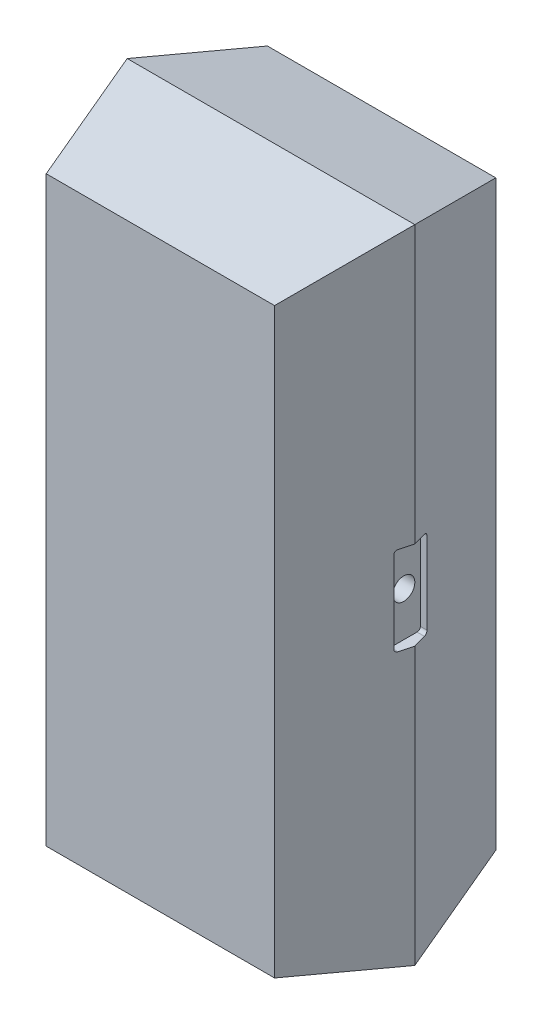
from build123d import *

# Parameters (mm, degrees)
ESBO_O15_W                         = 1.3
ESBO_O15_H                         = 2.9
RESSALTO_EXTRUS_O1_DEPTH           = 0.5
RESSALTO_EXTRUS_O1_TAPER           = 15
RESSALTO_EXTRUS_O1_OTHER_WAY_DEPTH = 0.5
RESSALTO_EXTRUS_O1_OTHER_WAY_TAPER = 15
ESBO_O18_R                         = 0.05
CORTE_EXTRUS_O1_DEPTH              = 1
ESBO_O18_3_R                       = 0.05
CORTE_EXTRUS_O2_DEPTH              = 1
CORTE_EXTRUS_O3_DEPTH              = 0.05
CORTE_EXTRUS_O4_START              = 1.3
CORTE_EXTRUS_O4_DEPTH              = 0.05


with BuildPart() as part:
    # Esbo_o15 → Ressalto-extrus_o1 (new body)
    with BuildSketch(Plane.XY.offset(0.5)):
        Rectangle(ESBO_O15_W, ESBO_O15_H)
    extrude(amount=-RESSALTO_EXTRUS_O1_DEPTH, taper=RESSALTO_EXTRUS_O1_TAPER)

    # Esbo_o15 → Ressalto-extrus_o1 other way (add)
    with BuildSketch(Plane.XY.offset(0.5)):
        Rectangle(ESBO_O15_W, ESBO_O15_H)
    extrude(amount=RESSALTO_EXTRUS_O1_OTHER_WAY_DEPTH, taper=RESSALTO_EXTRUS_O1_OTHER_WAY_TAPER)

    # Esbo_o18 → Corte-extrus_o1 (cut)
    with BuildSketch(Plane(origin=(0, 0, 0), x_dir=(0, 0, -1), z_dir=(1, 0, 0))):
        with Locations((-0.5, 0.95)):
            Circle(ESBO_O18_R)
        with Locations((-0.5, -0.95)):
            Circle(ESBO_O18_R)
    extrude(amount=-CORTE_EXTRUS_O1_DEPTH, mode=Mode.SUBTRACT)

    # Esbo_o18_3 → Corte-extrus_o2 (cut)
    with BuildSketch(Plane(origin=(0, 0, 0), x_dir=(0, 0, -1), z_dir=(1, 0, 0))):
        with Locations((-0.5, 0)):
            Circle(ESBO_O18_3_R)
    extrude(amount=CORTE_EXTRUS_O2_DEPTH, mode=Mode.SUBTRACT)

    # Esbo_o19 → Corte-extrus_o3 (cut)
    with BuildSketch(Plane(origin=(-0.65, 0, 0), x_dir=(0, 0, -1), z_dir=(1, 0, 0))):
        with BuildLine():
            Line((-0.44, 1.15), (-0.56, 1.15))
            ThreePointArc((-0.56, 1.15), (-0.570606602, 1.145606602), (-0.575, 1.135))
            Line((-0.575, 1.135), (-0.575, 0.765))
            ThreePointArc((-0.575, 0.765), (-0.570606602, 0.754393398), (-0.56, 0.75))
            Line((-0.56, 0.75), (-0.44, 0.75))
            ThreePointArc((-0.44, 0.75), (-0.429393398, 0.754393398), (-0.425, 0.765))
            Line((-0.425, 0.765), (-0.425, 1.135))
            ThreePointArc((-0.425, 1.135), (-0.429393398, 1.145606602), (-0.44, 1.15))
        make_face()
        with BuildLine():
            Line((-0.44, -0.75), (-0.56, -0.75))
            ThreePointArc((-0.56, -0.75), (-0.570606602, -0.754393398), (-0.575, -0.765))
            Line((-0.575, -0.765), (-0.575, -1.135))
            ThreePointArc((-0.575, -1.135), (-0.570606602, -1.145606602), (-0.56, -1.15))
            Line((-0.56, -1.15), (-0.44, -1.15))
            ThreePointArc((-0.44, -1.15), (-0.429393398, -1.145606602), (-0.425, -1.135))
            Line((-0.425, -1.135), (-0.425, -0.765))
            ThreePointArc((-0.425, -0.765), (-0.429393398, -0.754393398), (-0.44, -0.75))
        make_face()
    extrude(amount=CORTE_EXTRUS_O3_DEPTH, mode=Mode.SUBTRACT)

    # Esbo_o19_3 → Corte-extrus_o4 (cut)
    with BuildSketch(Plane(origin=(-0.65, 0, 0), x_dir=(0, 0, -1), z_dir=(1, 0, 0)).offset(CORTE_EXTRUS_O4_START)):
        with BuildLine():
            Line((-0.44, 0.2), (-0.56, 0.2))
            ThreePointArc((-0.56, 0.2), (-0.570606602, 0.195606602), (-0.575, 0.185))
            Line((-0.575, 0.185), (-0.575, -0.185))
            ThreePointArc((-0.575, -0.185), (-0.570606602, -0.195606602), (-0.56, -0.2))
            Line((-0.56, -0.2), (-0.44, -0.2))
            ThreePointArc((-0.44, -0.2), (-0.429393398, -0.195606602), (-0.425, -0.185))
            Line((-0.425, -0.185), (-0.425, 0.185))
            ThreePointArc((-0.425, 0.185), (-0.429393398, 0.195606602), (-0.44, 0.2))
        make_face()
    extrude(amount=-CORTE_EXTRUS_O4_DEPTH, mode=Mode.SUBTRACT)


solid = part.part
